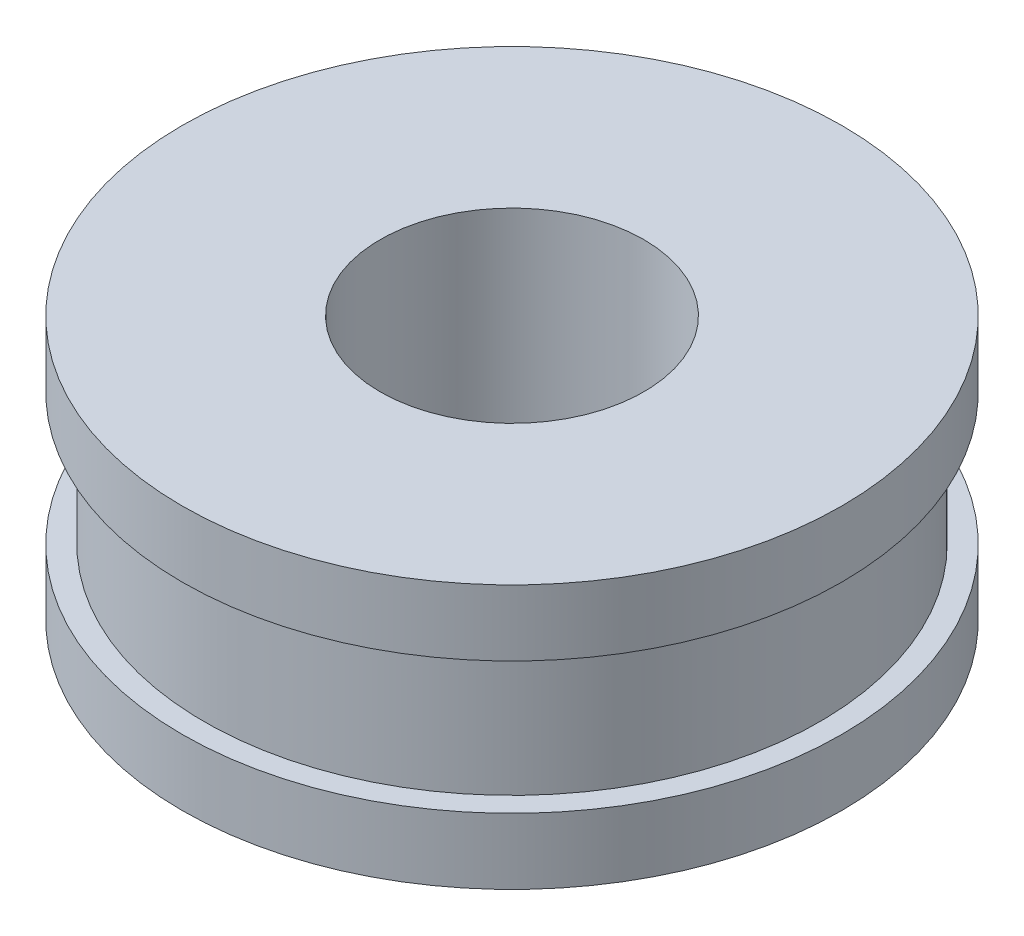
from build123d import *

# Parameters (mm, degrees)
SKETCH1_R           = 7.5
SKETCH1_R_2         = 3
BOSS_EXTRUDE1_DEPTH = 6
SKETCH2_W           = 0.5
SKETCH2_H           = 3


with BuildPart() as part:
    # Sketch1 → Boss-Extrude1 (new body)
    with BuildSketch(Plane(origin=(0, 0, 0), x_dir=(1, 0, 0), z_dir=(0, 1, 0))):
        Circle(SKETCH1_R)
        Circle(SKETCH1_R_2, mode=Mode.SUBTRACT)
    extrude(amount=BOSS_EXTRUDE1_DEPTH)

    # Sketch2 → Cut-Revolve1 (revolve, cut)
    with BuildSketch(Plane(origin=(0, 0, 0), x_dir=(0, 0, -1), z_dir=(1, 0, 0))):
        with Locations((7.25, 3)):
            Rectangle(SKETCH2_W, SKETCH2_H)
    revolve(axis=Axis((0, 0, 0), (0, 1, 0)), mode=Mode.SUBTRACT)


solid = part.part
